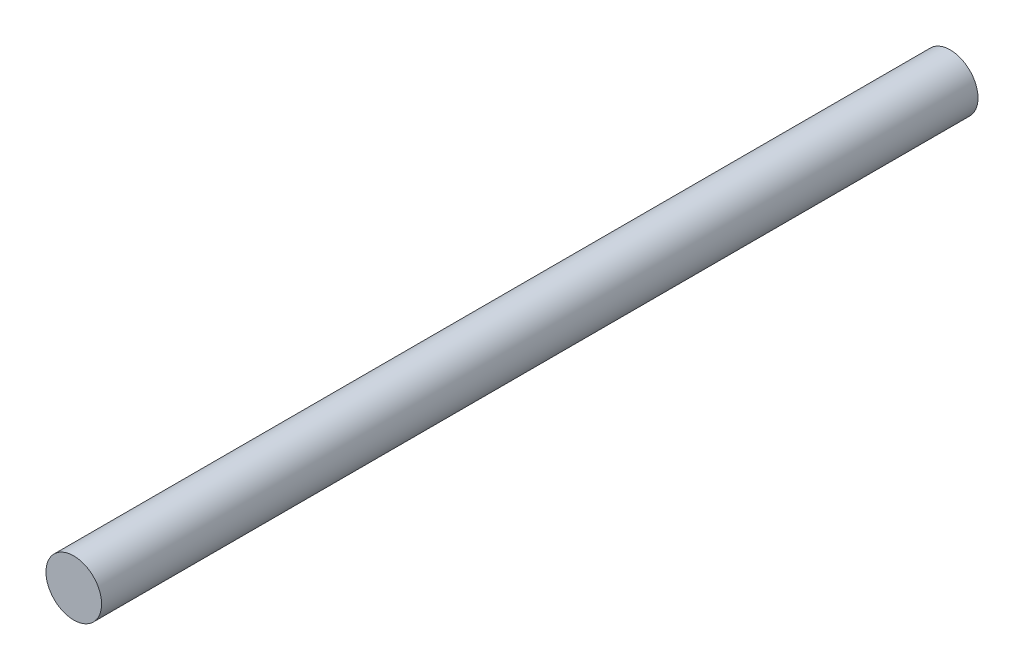
from build123d import *

# Parameters (mm, degrees)
SKICA1_R                = 1.65
P_IDAT_VYSUNUT_M1_DEPTH = 52


with BuildPart() as part:
    # Skica1 → Přidat vysunutím1 (new body)
    with BuildSketch(Plane.XY):
        Circle(SKICA1_R)
    extrude(amount=P_IDAT_VYSUNUT_M1_DEPTH)


solid = part.part
